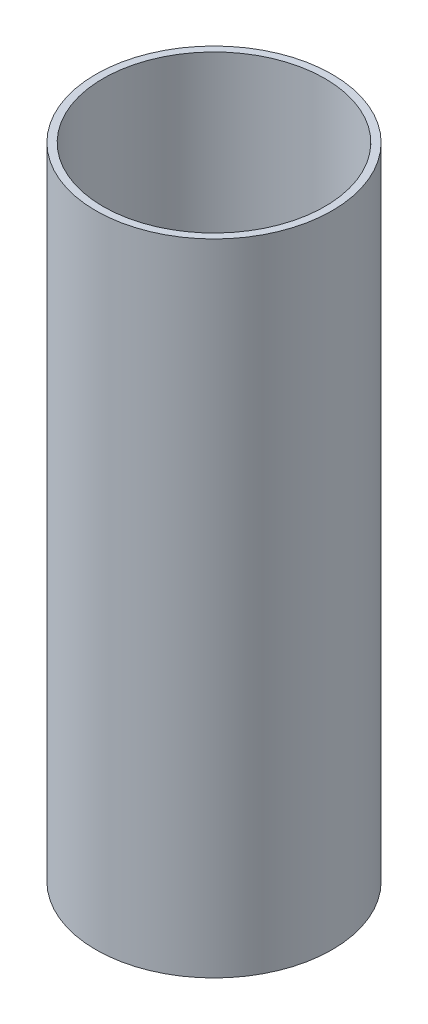
from build123d import *

# Parameters (mm, degrees)
SKETCH1_W = 3.175
SKETCH1_H = 279.4


with BuildPart() as part:
    # Sketch1 → Revolve1 (revolve)
    with BuildSketch(Plane.XY):
        with Locations((50.00625, 139.7)):
            Rectangle(SKETCH1_W, SKETCH1_H)
    revolve(axis=Axis((0, -13.97, 0), (0, 1, 0)))


solid = part.part
